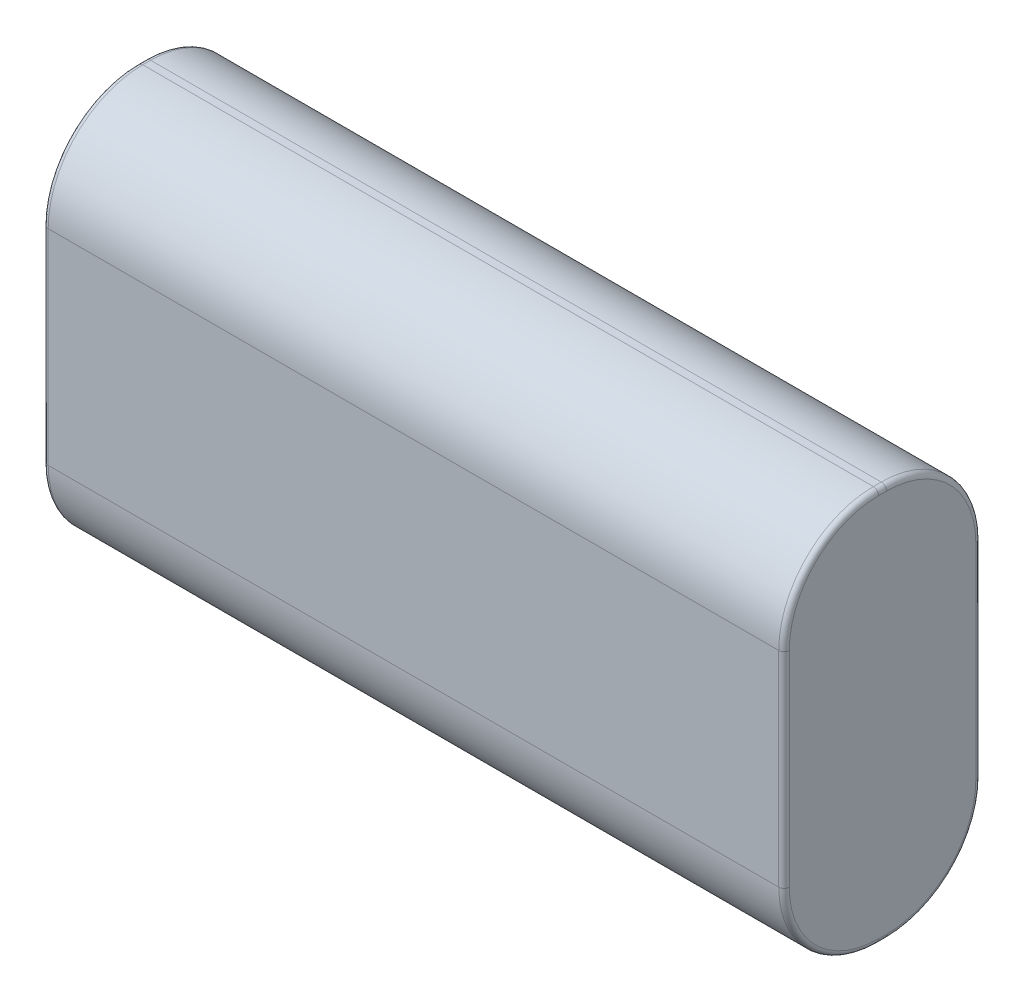
from build123d import *

# Parameters (mm, degrees)
SKETCH_1_W      = 18.75
SKETCH_1_H      = 37.5
EXTRUDE_1_DEPTH = 70.5
FILLET_1_R      = 9
FILLET_2_R      = 0.5


with BuildPart() as part:
    # 草图1 → 凸台-拉伸1 (new body)
    with BuildSketch(Plane(origin=(0, 0, 0), x_dir=(0, 0, -1), z_dir=(1, 0, 0))):
        with Locations((9.375, 18.75)):
            Rectangle(SKETCH_1_W, SKETCH_1_H)
    extrude(amount=EXTRUDE_1_DEPTH)

    # 圆角1
    fillet_1_edges = [part.edges().sort_by_distance(p)[0] for p in [
        (35.25, 37.5, 0),
        (35.25, 37.5, -18.75),
        (35.25, 0, -18.75),
        (35.25, 0, 0),
    ]]
    fillet(fillet_1_edges, radius=FILLET_1_R)

    # 圆角2
    fillet_2_edges = [part.edges().sort_by_distance(p)[0] for p in [
        (0, 18.75, -18.75),
        (70.5, 18.75, -18.75),
        (0, 18.75, 0),
        (0, 37.5, -9.375),
        (0, 0, -9.375),
        (0, 34.863961031, -2.636038969),
        (0, 34.863961031, -16.113961031),
        (0, 2.636038969, -2.636038969),
        (0, 2.636038969, -16.113961031),
        (70.5, 0, -9.375),
        (70.5, 18.75, 0),
        (70.5, 37.5, -9.375),
        (70.5, 34.863961031, -2.636038969),
        (70.5, 34.863961031, -16.113961031),
        (70.5, 2.636038969, -2.636038969),
        (70.5, 2.636038969, -16.113961031),
    ]]
    fillet(fillet_2_edges, radius=FILLET_2_R)


solid = part.part
